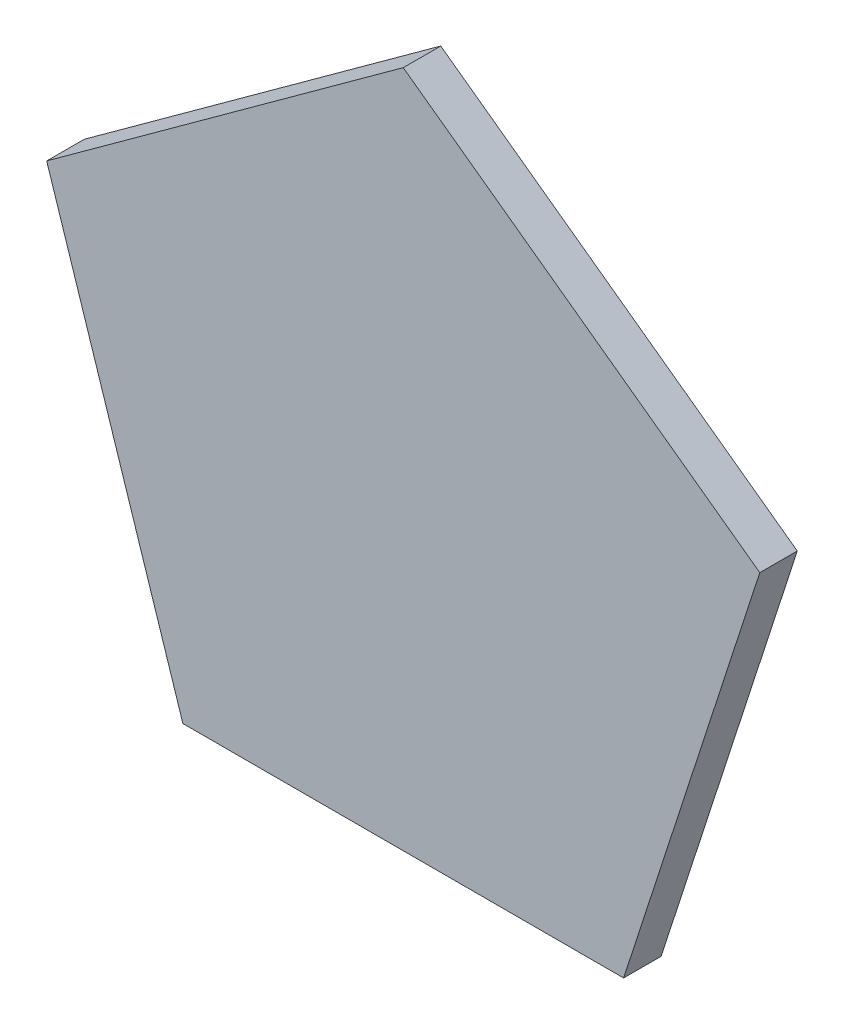
from build123d import *

# Parameters (mm, degrees)
SALIENTE_EXTRUIR1_DEPTH = 1
SALIENTE_EXTRUIR2_DEPTH = 0.5


with BuildPart() as part:
    # Croquis1 → Saliente-Extruir1 (new body)
    with BuildSketch(Plane.XY):
        Polygon((5.877852523, -8.090169944), (9.510565163, 3.090169944), (0, 10), (-9.510565163, 3.090169944), (-5.877852523, -8.090169944), align=None)
        Polygon((9.040336961, 2.937383539), (0, 9.505572809), (-9.040336961, 2.937383539), (-5.587235512, -7.690169944), (5.587235512, -7.690169944), align=None, mode=Mode.SUBTRACT)
        Polygon((0.20966269, 9.353243948), (0, 9.505572809), (-0.210923368, 9.352328012), (-2.250282014, 3.090169944), (-8.830044516, 3.090169944), (-9.040336961, 2.937383539), (-8.960012395, 2.690169944), (-3.585831742, -1.214400854), (-5.664867685, -7.451242681), (-5.587235512, -7.690169944), (-5.318402678, -7.690169944), (-0.017323898, -3.899961523), (5.315095177, -7.690169944), (5.587235512, -7.690169944), (5.66389501, -7.454236269), (3.568710751, -1.226839982), (8.960012395, 2.690169944), (9.040336961, 2.937383539), (8.830044516, 3.090169944), (2.24, 3.090169944), align=None)
    extrude(amount=-SALIENTE_EXTRUIR1_DEPTH)

    # Croquis1_3 → Saliente-Extruir2 (add)
    with BuildSketch(Plane.XY):
        Polygon((8.830044516, 3.090169944), (0.20966269, 9.353243948), (2.24, 3.090169944), align=None)
        Polygon((-2.250282014, 3.090169944), (-0.210923368, 9.352328012), (-8.830044516, 3.090169944), align=None)
        Polygon((-3.585831742, -1.214400854), (-8.960012395, 2.690169944), (-5.664867685, -7.451242681), align=None)
        Polygon((-0.017323898, -3.899961523), (-5.318402678, -7.690169944), (5.315095177, -7.690169944), align=None)
        Polygon((5.66389501, -7.454236269), (8.960012395, 2.690169944), (3.568710751, -1.226839982), align=None)
    extrude(amount=-SALIENTE_EXTRUIR2_DEPTH)


solid = part.part
